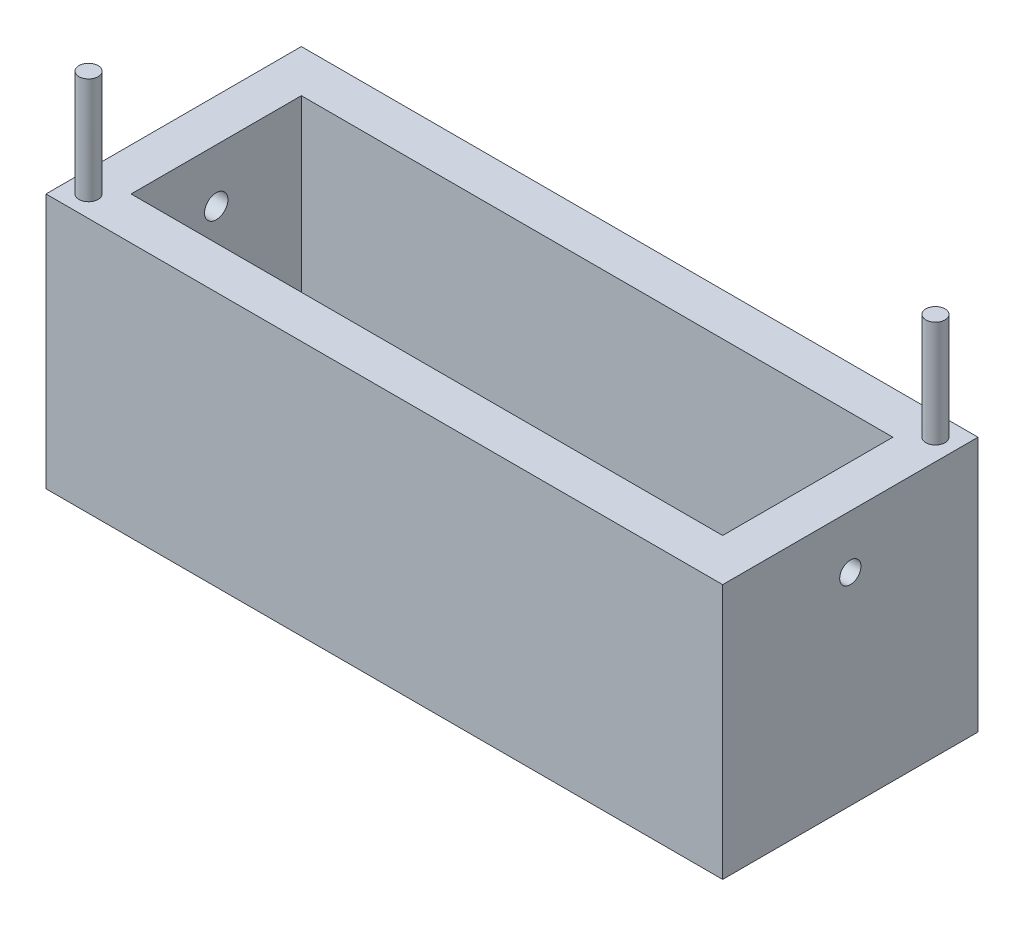
from build123d import *

# Parameters (mm, degrees)
SKETCH1_W           = 403.86
SKETCH1_H           = 152.4
BOSS_EXTRUDE1_DEPTH = 152.4
SKETCH3_W           = 353.06
SKETCH3_H           = 101.6
CUT_EXTRUDE1_DEPTH  = 139.7
SKETCH11_R          = 5.715
BOSS_EXTRUDE3_DEPTH = 63.5
SKETCH13_R          = 5.715
BOSS_EXTRUDE4_DEPTH = 63.5
SKETCH15_R          = 6.35
CUT_EXTRUDE2_DEPTH  = 63.5
SKETCH16_R          = 6.985
CUT_EXTRUDE3_DEPTH  = 63.5


with BuildPart() as part:
    # Sketch1 → Boss-Extrude1 (new body)
    with BuildSketch(Plane(origin=(0, 0, 0), x_dir=(1, 0, 0), z_dir=(0, 1, 0))):
        with Locations((201.93, 76.2)):
            Rectangle(SKETCH1_W, SKETCH1_H)
    extrude(amount=BOSS_EXTRUDE1_DEPTH)

    # Sketch3 → Cut-Extrude1 (cut)
    with BuildSketch(Plane(origin=(0, 152.4, 0), x_dir=(1, 0, 0), z_dir=(0, 1, 0))):
        with Locations((201.93, 76.2)):
            Rectangle(SKETCH3_W, SKETCH3_H)
    extrude(amount=-CUT_EXTRUDE1_DEPTH, mode=Mode.SUBTRACT)

    # Sketch11 → Boss-Extrude3 (add)
    with BuildSketch(Plane(origin=(0, 152.4, 0), x_dir=(1, 0, 0), z_dir=(0, 1, 0))):
        with Locations((12.7, 12.7)):
            Circle(SKETCH11_R)
    extrude(amount=BOSS_EXTRUDE3_DEPTH)

    # Sketch13 → Boss-Extrude4 (add)
    with BuildSketch(Plane(origin=(0, 152.4, 0), x_dir=(1, 0, 0), z_dir=(0, 1, 0))):
        with Locations((391.16, 139.7)):
            Circle(SKETCH13_R)
    extrude(amount=BOSS_EXTRUDE4_DEPTH)

    # Sketch15 → Cut-Extrude2 (cut)
    with BuildSketch(Plane(origin=(403.86, 0, 0), x_dir=(0, 0, -1), z_dir=(1, 0, 0))):
        with Locations((76.2, 120.65)):
            Circle(SKETCH15_R)
    extrude(amount=-CUT_EXTRUDE2_DEPTH, mode=Mode.SUBTRACT)

    # Sketch16 → Cut-Extrude3 (cut)
    with BuildSketch(Plane.ZY):
        with Locations((-76.2, 120.65)):
            Circle(SKETCH16_R)
    extrude(amount=-CUT_EXTRUDE3_DEPTH, mode=Mode.SUBTRACT)


solid = part.part
